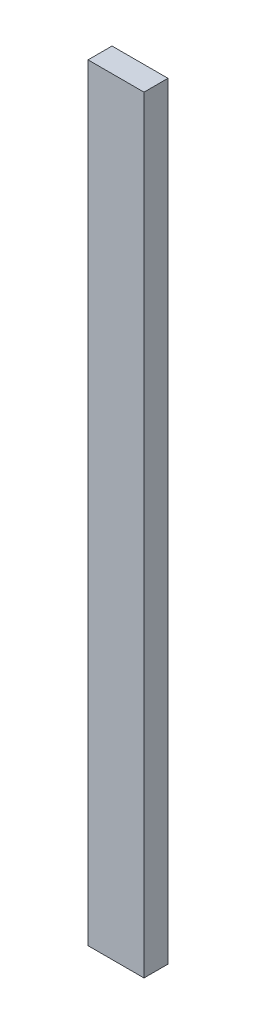
from build123d import *

# Parameters (mm, degrees)
SKETCH2_W           = 88.9
SKETCH2_H           = 1219.2
BOSS_EXTRUDE1_DEPTH = 38.1


with BuildPart() as part:
    # Sketch2 → Boss-Extrude1 (new body)
    with BuildSketch(Plane.XY):
        with Locations((44.45, 609.6)):
            Rectangle(SKETCH2_W, SKETCH2_H)
    extrude(amount=BOSS_EXTRUDE1_DEPTH)


solid = part.part
